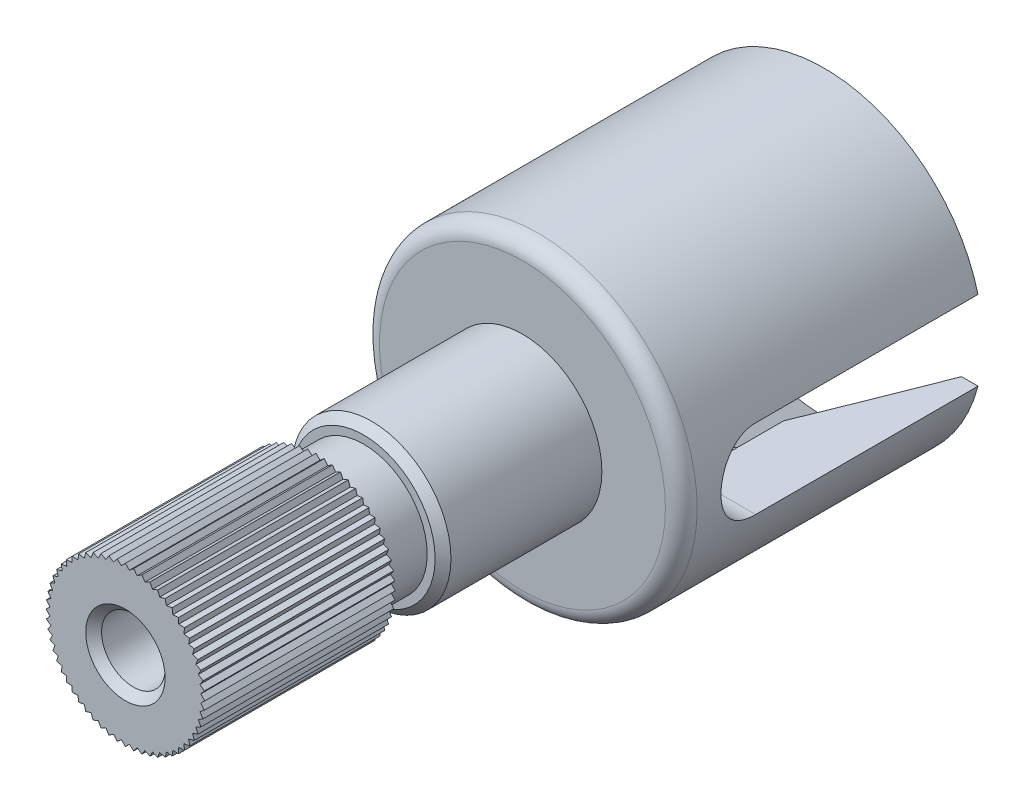
from build123d import *

# Parameters (mm, degrees)
ESQUISSE1_R             = 5
BASE_EXTRUSION_DEPTH    = 9.5
ESQUISSE2_R             = 2.5
BOSS_EXTRU_1_DEPTH      = 5
CONG_1_R                = 0.5
ENL_V_MAT_EXTRU_1_DEPTH = 16
ESQUISSE11_R            = 2
BOSS_EXTRU_2_DEPTH      = 1.5
BOSS_EXTRU_3_DEPTH      = 6
ESQUISSE13_R            = 1
ENL_V_MAT_EXTRU_2_DEPTH = 18
CHANFREIN1_SIZE         = 0.25


with BuildPart() as part:
    # Esquisse1 → Base-Extrusion (new body)
    with BuildSketch(Plane.XY):
        Circle(ESQUISSE1_R)
    extrude(amount=BASE_EXTRUSION_DEPTH)

    # Esquisse2 → Boss.-Extru.1 (add)
    with BuildSketch(Plane.XY.offset(9.5)):
        Circle(ESQUISSE2_R)
    extrude(amount=BOSS_EXTRU_1_DEPTH)

    # Congé1
    cong_1_edges = [part.edges().sort_by_distance(p)[0] for p in [
        (-5, 0, 9.5),
    ]]
    fillet(cong_1_edges, radius=CONG_1_R)

    # Esquisse7 → Enlèv. mat.-Extru.1 (cut, symmetric)
    with BuildSketch(Plane(origin=(0, 0, 0), x_dir=(0, 0, -1), z_dir=(1, 0, 0))):
        with BuildLine():
            Line((1, 1.25), (-7, 1.25))
            ThreePointArc((-7, 1.25), (-8.25, 0), (-7, -1.25))
            Line((-7, -1.25), (1, -1.25))
            Line((1, -1.25), (1, 1.25))
        make_face()
    extrude(amount=ENL_V_MAT_EXTRU_1_DEPTH, both=True, mode=Mode.SUBTRACT)

    # Esquisse8 → Enlèvement de matière-Révolution1 (revolve, cut)
    with BuildSketch(Plane(origin=(0, 0, 0), x_dir=(0, 0, -1), z_dir=(1, 0, 0))):
        Polygon((0, 4.5), (-4, 3), (-8, 3), (-9.5, 0), (0, 0), align=None)
    revolve(axis=Axis((0, 0, 0), (0, 0, 1)), mode=Mode.SUBTRACT)

    # Esquisse11 → Boss.-Extru.2 (add)
    with BuildSketch(Plane.XY.offset(14.5)):
        Circle(ESQUISSE11_R)
    extrude(amount=BOSS_EXTRU_2_DEPTH)

    # Esquisse12 → Boss.-Extru.3 (add)
    with BuildSketch(Plane.XY.offset(16)):
        Polygon((-0.124297896, 2.371745145), (0, 2.5), (0.124297896, 2.371745145), (0.261321158, 2.486304738), (0.371531854, 2.345759809), (0.519779227, 2.445369002), (0.614695232, 2.294073837), (0.772542486, 2.377641291), (0.85112388, 2.217253513), (1.016841608, 2.283863644), (1.078227437, 2.116140495), (1.25, 2.165063509), (1.293517708, 1.991842599), (1.469463131, 2.022542486), (1.494635929, 1.845721658), (1.672826516, 1.857862064), (1.679378605, 1.679378605), (1.857862064, 1.672826516), (1.845721658, 1.494635929), (2.022542486, 1.469463131), (1.991842599, 1.293517708), (2.165063509, 1.25), (2.116140495, 1.078227437), (2.283863644, 1.016841608), (2.217253513, 0.85112388), (2.377641291, 0.772542486), (2.294073837, 0.614695232), (2.445369002, 0.519779227), (2.345759809, 0.371531854), (2.486304738, 0.261321158), (2.371745145, 0.124297896), (2.5, 0), (2.371745145, -0.124297896), (2.486304738, -0.261321158), (2.345759809, -0.371531854), (2.445369002, -0.519779227), (2.294073837, -0.614695232), (2.377641291, -0.772542486), (2.217253513, -0.85112388), (2.283863644, -1.016841608), (2.116140495, -1.078227437), (2.165063509, -1.25), (1.991842599, -1.293517708), (2.022542486, -1.469463131), (1.845721658, -1.494635929), (1.857862064, -1.672826516), (1.679378605, -1.679378605), (1.672826516, -1.857862064), (1.494635929, -1.845721658), (1.469463131, -2.022542486), (1.293517708, -1.991842599), (1.25, -2.165063509), (1.078227437, -2.116140495), (1.016841608, -2.283863644), (0.85112388, -2.217253513), (0.772542486, -2.377641291), (0.614695232, -2.294073837), (0.519779227, -2.445369002), (0.371531854, -2.345759809), (0.261321158, -2.486304738), (0.124297896, -2.371745145), (0, -2.5), (-0.124297896, -2.371745145), (-0.261321158, -2.486304738), (-0.371531854, -2.345759809), (-0.519779227, -2.445369002), (-0.614695232, -2.294073837), (-0.772542486, -2.377641291), (-0.85112388, -2.217253513), (-1.016841608, -2.283863644), (-1.078227437, -2.116140495), (-1.25, -2.165063509), (-1.293517708, -1.991842599), (-1.469463131, -2.022542486), (-1.494635929, -1.845721658), (-1.672826516, -1.857862064), (-1.679378605, -1.679378605), (-1.857862064, -1.672826516), (-1.845721658, -1.494635929), (-2.022542486, -1.469463131), (-1.991842599, -1.293517708), (-2.165063509, -1.25), (-2.116140495, -1.078227437), (-2.283863644, -1.016841608), (-2.217253513, -0.85112388), (-2.377641291, -0.772542486), (-2.294073837, -0.614695232), (-2.445369002, -0.519779227), (-2.345759809, -0.371531854), (-2.486304738, -0.261321158), (-2.371745145, -0.124297896), (-2.5, 0), (-2.371745145, 0.124297896), (-2.486304738, 0.261321158), (-2.345759809, 0.371531854), (-2.445369002, 0.519779227), (-2.294073837, 0.614695232), (-2.377641291, 0.772542486), (-2.217253513, 0.85112388), (-2.283863644, 1.016841608), (-2.116140495, 1.078227437), (-2.165063509, 1.25), (-1.991842599, 1.293517708), (-2.022542486, 1.469463131), (-1.845721658, 1.494635929), (-1.857862064, 1.672826516), (-1.679378605, 1.679378605), (-1.672826516, 1.857862064), (-1.494635929, 1.845721658), (-1.469463131, 2.022542486), (-1.293517708, 1.991842599), (-1.25, 2.165063509), (-1.078227437, 2.116140495), (-1.016841608, 2.283863644), (-0.85112388, 2.217253513), (-0.772542486, 2.377641291), (-0.614695232, 2.294073837), (-0.519779227, 2.445369002), (-0.371531854, 2.345759809), (-0.261321158, 2.486304738), align=None)
    extrude(amount=BOSS_EXTRU_3_DEPTH)

    # Esquisse13 → Enlèv. mat.-Extru.2 (cut)
    with BuildSketch(Plane.XY.offset(22)):
        Circle(ESQUISSE13_R)
    extrude(amount=-ENL_V_MAT_EXTRU_2_DEPTH, mode=Mode.SUBTRACT)

    # Chanfrein1
    chanfrein1_edges = [part.edges().sort_by_distance(p)[0] for p in [
        (-1, 0, 22),
        (-2.5, 0, 14.5),
    ]]
    chamfer(chanfrein1_edges, length=CHANFREIN1_SIZE)


solid = part.part
